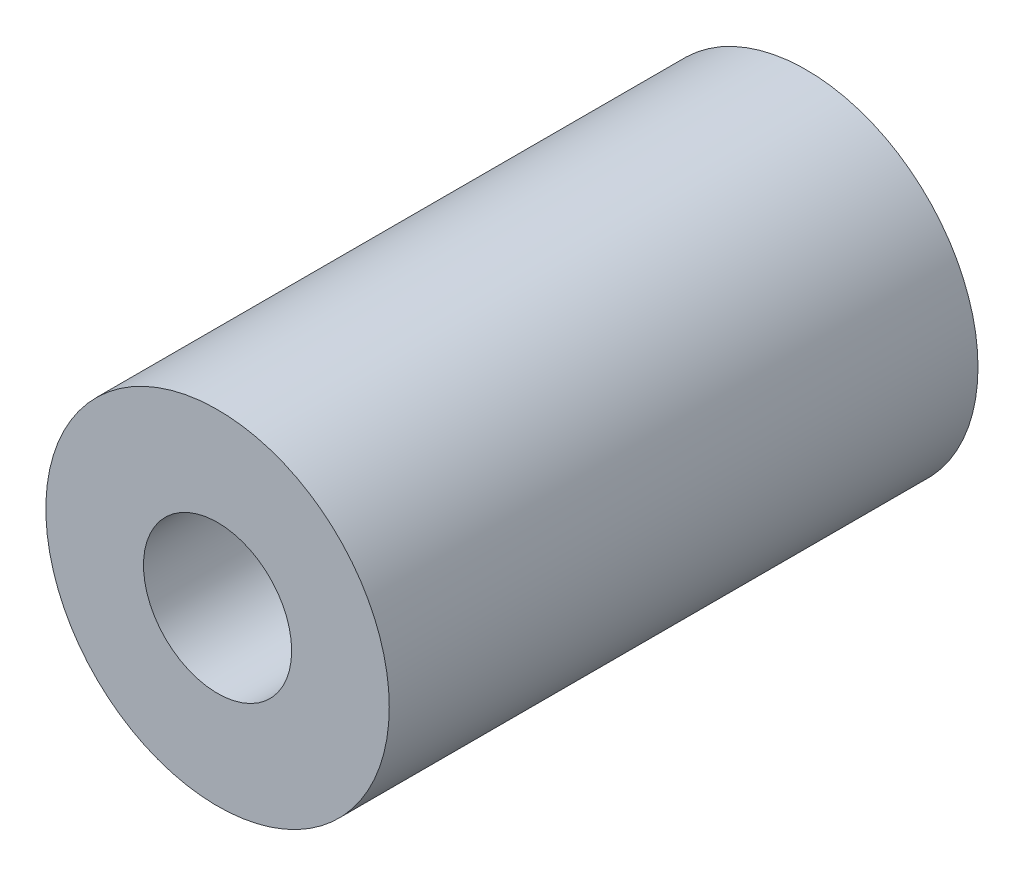
from build123d import *

# Parameters (mm, degrees)
ESQUISSE1_R             = 17.5
BOSS_EXTRU_1_DEPTH      = 30
ENL_V_START             = -30
ESQUISSE2_R             = 7.55
ENL_V_MAT_EXTRU_1_DEPTH = 30
ESQUISSE3_R             = 10.05
ENL_V_MAT_EXTRU_2_DEPTH = 30


with BuildPart() as part:
    # Esquisse1 → Boss.-Extru.1 (new body, symmetric)
    with BuildSketch(Plane.XY):
        Circle(ESQUISSE1_R)
    extrude(amount=BOSS_EXTRU_1_DEPTH, both=True)

    # Esquisse2 → Enlèv. mat.-Extru.1 (cut)
    with BuildSketch(Plane.XY.offset(30).offset(ENL_V_START)):
        Circle(ESQUISSE2_R)
    extrude(amount=ENL_V_MAT_EXTRU_1_DEPTH, mode=Mode.SUBTRACT)

    # Esquisse3 → Enlèv. mat.-Extru.2 (cut)
    with BuildSketch(Plane(origin=(0, 0, -30), x_dir=(-1, 0, 0), z_dir=(0, 0, -1)).offset(ENL_V_START)):
        Circle(ESQUISSE3_R)
    extrude(amount=ENL_V_MAT_EXTRU_2_DEPTH, mode=Mode.SUBTRACT)


solid = part.part
